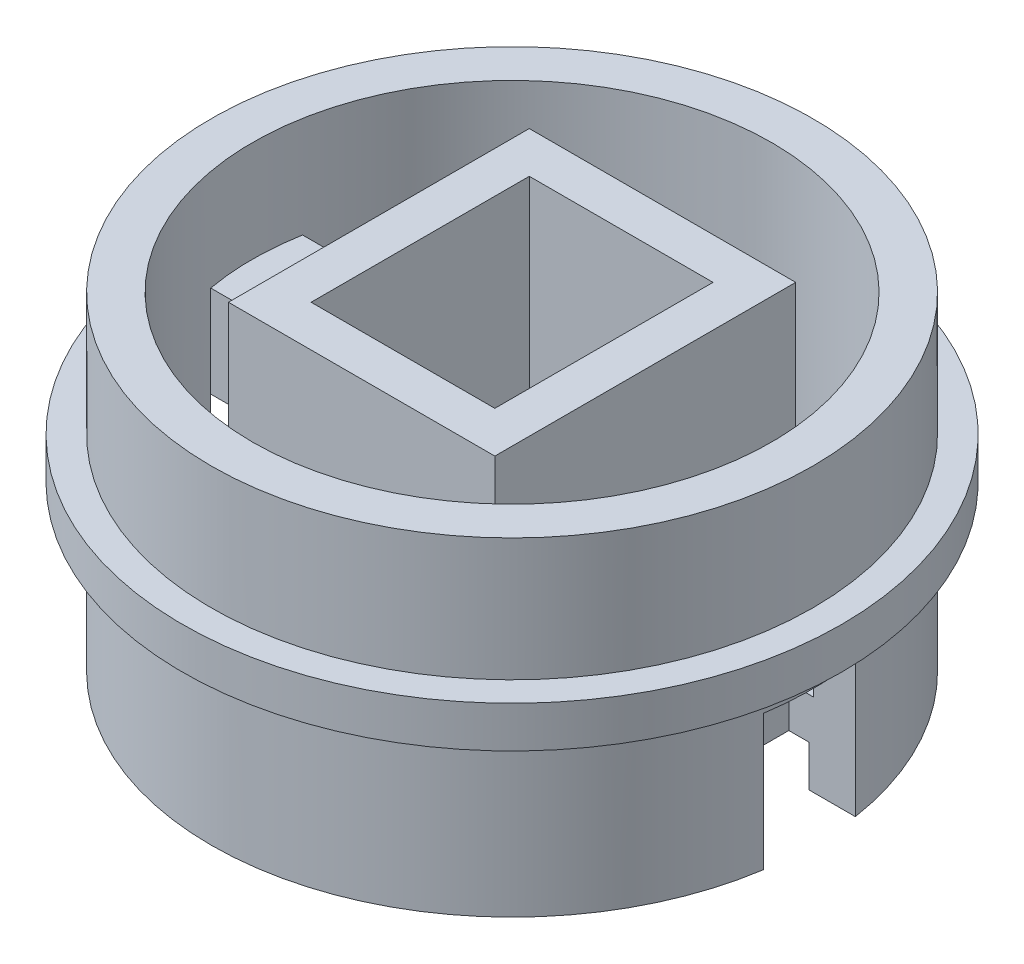
from build123d import *

# Parameters (mm, degrees)
SKETCH1_R           = 16.637
SKETCH1_W           = 10.16
SKETCH1_H           = 12.065
BOSS_EXTRUDE1_DEPTH = 15.875
SHELL1_T            = -2.286
BOSS_EXTRUDE2_DEPTH = 1.5875
SKETCH3_W           = 1.5875
SKETCH3_H           = 5.08
BOSS_EXTRUDE3_DEPTH = 13.589
SKETCH7_R           = 16.637
SKETCH7_R_2         = 14.097
BOSS_EXTRUDE4_DEPTH = 2.286
CUT_EXTRUDE1_DEPTH  = 7.493
CUT_EXTRUDE2_DEPTH  = 5.588
CIRPATTERN2_COUNT   = 2
SKETCH6_W           = 1.5875
SKETCH6_H           = 2.286


with BuildPart() as part:
    # Sketch1 → Boss-Extrude1 (new body)
    with BuildSketch(Plane(origin=(0, 0, 0), x_dir=(1, 0, 0), z_dir=(0, 1, 0))):
        with Locations(Location((0, 0, 0), (0, 0, 270))):
            Circle(SKETCH1_R)
        Rectangle(SKETCH1_W, SKETCH1_H, mode=Mode.SUBTRACT)
    extrude(amount=BOSS_EXTRUDE1_DEPTH)

    # Shell1
    shell1_openings = [part.faces().sort_by_distance(p)[0] for p in [
        (0, 15.875, -16.166434579),
    ]]
    offset(amount=SHELL1_T, openings=shell1_openings, kind=Kind.INTERSECTION)

    # Sketch2 → Boss-Extrude2 (add)
    with BuildSketch(Plane.XZ):
        Polygon((-5.08, 6.0325), (-1.905, 6.0325), (-5.08, 2.8575), align=None)
        Polygon((5.08, -2.8575), (1.905, -6.0325), (5.08, -6.0325), align=None)
    extrude(amount=-BOSS_EXTRUDE2_DEPTH)

    # Sketch3 → Boss-Extrude3 (add)
    with BuildSketch(Plane(origin=(0, 15.875, 0), x_dir=(1, 0, 0), z_dir=(0, 1, 0))):
        with Locations((-13.55725, 0)):
            Rectangle(SKETCH3_W, SKETCH3_H)
    boss_extrude3 = extrude(amount=-BOSS_EXTRUDE3_DEPTH)

    # Sketch7 → Boss-Extrude4 (add)
    with BuildSketch(Plane.XZ):
        with Locations(Location((0, 0, 0), (0, 0, 270))):
            Circle(SKETCH7_R)
        with Locations(Location((0, 0, 0), (0, 0, 270))):
            Circle(SKETCH7_R_2, mode=Mode.SUBTRACT)
    extrude(amount=BOSS_EXTRUDE4_DEPTH)

    # Sketch4 → Cut-Extrude1 (cut)
    with BuildSketch(Plane.XZ.offset(2.286)):
        with BuildLine():
            Line((-16.44196366, -2.54), (-12.7635, -2.54))
            Line((-12.7635, -2.54), (-12.7635, 2.54))
            Line((-12.7635, 2.54), (-16.44196366, 2.54))
            ThreePointArc((-16.44196366, 2.54), (-16.637, 0), (-16.44196366, -2.54))
        make_face()
    cut_extrude1 = extrude(amount=-CUT_EXTRUDE1_DEPTH, mode=Mode.SUBTRACT)

    # Sketch5 → Cut-Extrude2 (cut)
    with BuildSketch(Plane(origin=(0, 15.875, 0), x_dir=(1, 0, 0), z_dir=(0, 1, 0))):
        with BuildLine():
            Line((-14.124432767, -2.54), (-12.7635, -2.54))
            Line((-12.7635, -2.54), (-12.7635, 2.54))
            Line((-12.7635, 2.54), (-14.124432767, 2.54))
            ThreePointArc((-14.124432767, 2.54), (-14.351, 0), (-14.124432767, -2.54))
        make_face()
    cut_extrude2 = extrude(amount=-CUT_EXTRUDE2_DEPTH, mode=Mode.SUBTRACT)

    # CirPattern2: Boss-Extrude3, Cut-Extrude1, Cut-Extrude2 ×2 about axis
    cirpattern2_axis = Axis((0, 0, 0), (0, 1, 0))
    add([boss_extrude3.rotate(cirpattern2_axis, i * 360 / CIRPATTERN2_COUNT) for i in range(1, CIRPATTERN2_COUNT)])
    add([cut_extrude1.rotate(cirpattern2_axis, i * 360 / CIRPATTERN2_COUNT) for i in range(1, CIRPATTERN2_COUNT)], mode=Mode.SUBTRACT)
    add([cut_extrude2.rotate(cirpattern2_axis, i * 360 / CIRPATTERN2_COUNT) for i in range(1, CIRPATTERN2_COUNT)], mode=Mode.SUBTRACT)

    # Sketch6 → Revolve1 (revolve)
    with BuildSketch(Plane.XY, mode=Mode.PRIVATE) as revolve1_sk:
        with Locations((-17.43075, 7.9375)):
            Rectangle(SKETCH6_W, SKETCH6_H)
    revolve(revolve1_sk.sketch.rotate(Axis((0, 0, 0), (0, 1, 0)), 188.781790598), axis=Axis((0, 0, 0), (0, 1, 0)))


solid = part.part
